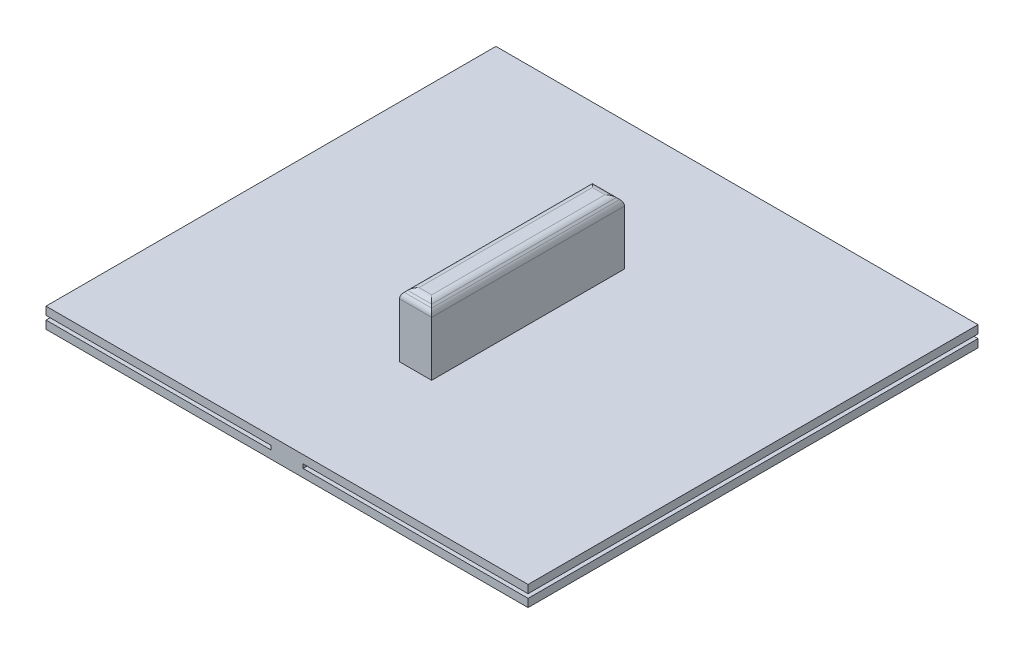
from build123d import *

# Parameters (mm, degrees)
BOSS_EXTRUDE1_DEPTH = 35.56
SKETCH2_W           = 2.54
SKETCH2_H           = 5.08
CUT_EXTRUDE1_DEPTH  = 10.16
SKETCH3_W           = 2.54
SKETCH3_H           = 5.08
CUT_EXTRUDE2_DEPTH  = 10.16
CHAMFER1_SIZE       = 0.508
FILLET1_R           = 0.635


with BuildPart() as part:
    # Sketch1 → Boss-Extrude1 (new body)
    with BuildSketch(Plane.XY):
        Polygon((-19.05, -0.3175), (-19.05, 0.3175), (-1.27, 0.3175), (-1.27, 5.3975), (1.27, 5.3975), (1.27, 0.3175), (19.05, 0.3175), (19.05, -0.3175), (1.27, -0.3175), (1.27, -0.635), (19.05, -0.635), (19.05, -1.27), (-19.05, -1.27), (-19.05, -0.635), (-1.27, -0.635), (-1.27, -0.3175), align=None)
    extrude(amount=-BOSS_EXTRUDE1_DEPTH)

    # Sketch2 → Cut-Extrude1 (cut)
    with BuildSketch(Plane.XY):
        with Locations((0, 2.8575)):
            Rectangle(SKETCH2_W, SKETCH2_H)
    extrude(amount=-CUT_EXTRUDE1_DEPTH, mode=Mode.SUBTRACT)

    # Sketch3 → Cut-Extrude2 (cut)
    with BuildSketch(Plane(origin=(0, 0, -35.56), x_dir=(-1, 0, 0), z_dir=(0, 0, -1))):
        with Locations((0, 2.8575)):
            Rectangle(SKETCH3_W, SKETCH3_H)
    extrude(amount=-CUT_EXTRUDE2_DEPTH, mode=Mode.SUBTRACT)

    # Chamfer1
    chamfer1_edges = [part.edges().sort_by_distance(p)[0] for p in [
        (0, 5.3975, -10.16),
        (1.27, 5.3975, -17.78),
        (-1.27, 5.3975, -17.78),
        (0, 5.3975, -25.4),
    ]]
    chamfer(chamfer1_edges, length=CHAMFER1_SIZE)

    # Fillet1
    fillet1_edges = [part.edges().sort_by_distance(p)[0] for p in [
        (1.27, 4.8895, -17.78),
        (0, 5.3975, -24.892),
        (-0.762, 5.3975, -17.78),
        (0, 5.3975, -10.668),
        (0.762, 5.3975, -17.78),
        (0, 4.8895, -10.16),
        (-1.27, 4.8895, -17.78),
        (0, 4.8895, -25.4),
    ]]
    fillet(fillet1_edges, radius=FILLET1_R)


solid = part.part
